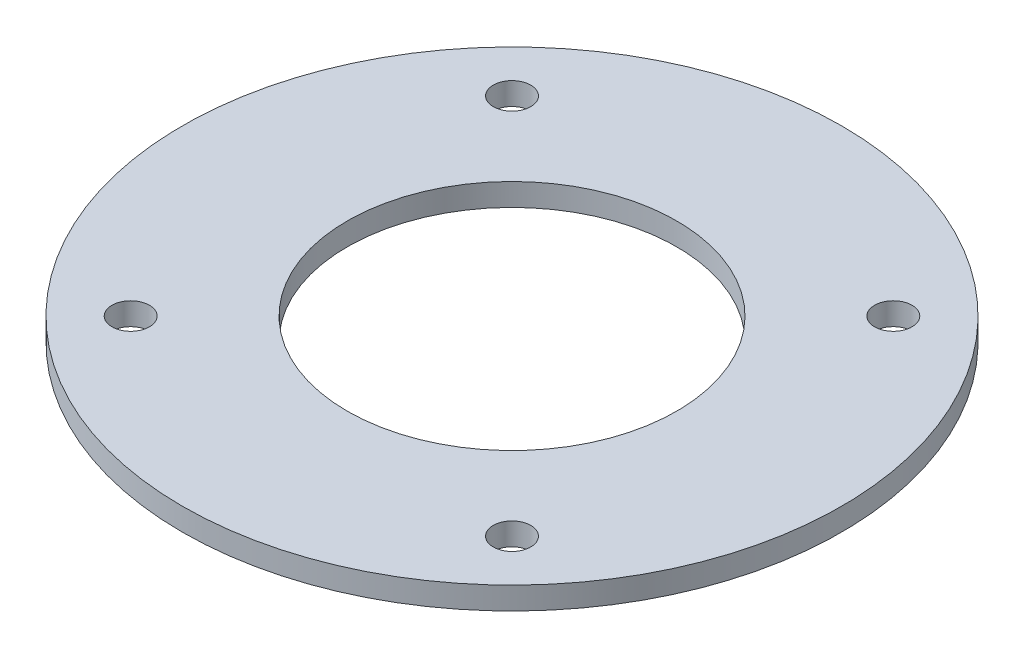
from build123d import *

# Parameters (mm, degrees)
SKETCH1_R           = 139.7
SKETCH1_R_2         = 69.85
SKETCH1_R_3         = 7.9375
BOSS_EXTRUDE1_DEPTH = 9.525


with BuildPart() as part:
    # Sketch1 → Boss-Extrude1 (new body)
    with BuildSketch(Plane(origin=(0, 0, 0), x_dir=(1, 0, 0), z_dir=(0, 1, 0))):
        with Locations((-50.749179719, 92.652131738)):
            Circle(SKETCH1_R)
        with Locations((-50.749179719, 92.652131738)):
            Circle(SKETCH1_R_2, mode=Mode.SUBTRACT)
        with Locations((-131.571484808, 173.474436827)):
            Circle(SKETCH1_R_3, mode=Mode.SUBTRACT)
        with Locations((-131.571484808, 11.829826648)):
            Circle(SKETCH1_R_3, mode=Mode.SUBTRACT)
        with Locations((30.073125371, 11.829826648)):
            Circle(SKETCH1_R_3, mode=Mode.SUBTRACT)
        with Locations((30.073125371, 173.474436827)):
            Circle(SKETCH1_R_3, mode=Mode.SUBTRACT)
    extrude(amount=BOSS_EXTRUDE1_DEPTH)


solid = part.part
